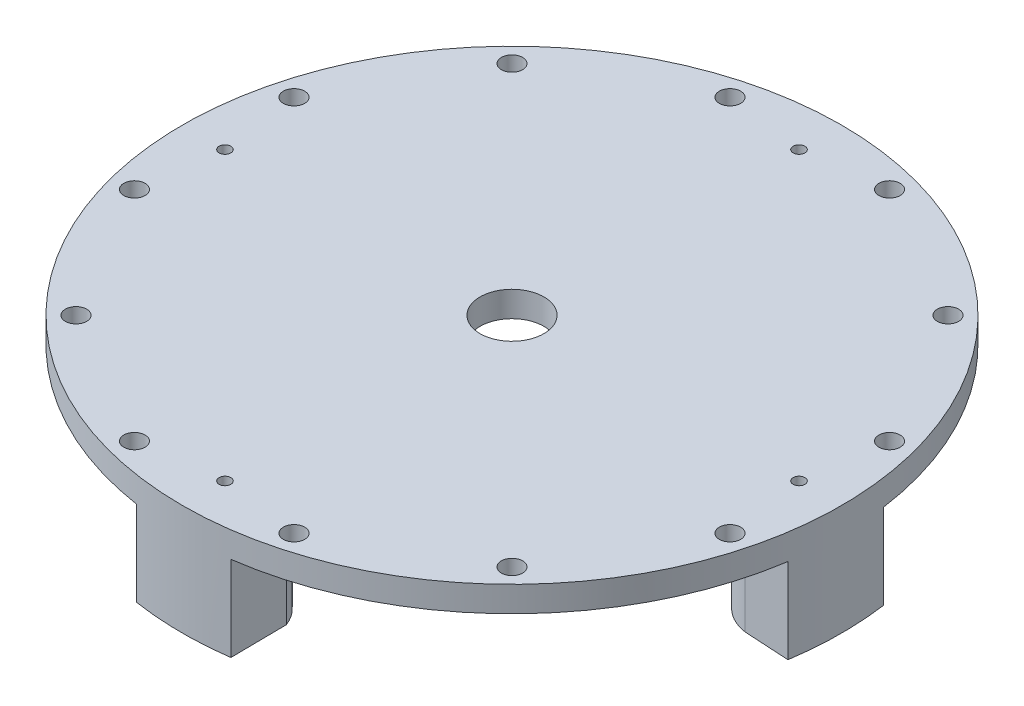
from build123d import *

# Parameters (mm, degrees)
SKETCH1_R           = 98.425
SKETCH1_R_2         = 9.525
BOSS_EXTRUDE1_DEPTH = 7.62
BOSS_EXTRUDE2_DEPTH = 25.4
SKETCH5_R           = 5.2578
CUT_EXTRUDE3_DEPTH  = 19.05
SKETCH6_R           = 3.175
CUT_EXTRUDE4_DEPTH  = 12.7
CIRPATTERN1_COUNT   = 12
CIRPATTERN2_COUNT   = 4
SKETCH8_R           = 1.7526
CUT_EXTRUDE6_DEPTH  = 34.02
CIRPATTERN3_COUNT   = 4


with BuildPart() as part:
    # Sketch1 → Boss-Extrude1 (new body)
    with BuildSketch(Plane(origin=(0, 0, 0), x_dir=(1, 0, 0), z_dir=(0, 1, 0))):
        Circle(SKETCH1_R)
        Circle(SKETCH1_R_2, mode=Mode.SUBTRACT)
    extrude(amount=BOSS_EXTRUDE1_DEPTH)

    # Sketch2 → Boss-Extrude2 (add)
    with BuildSketch(Plane.XZ):
        with BuildLine():
            Line((-14.092921054, 83.751577801), (-14.875155352, 97.29445194))
            ThreePointArc((-14.875155352, 97.29445194), (-0.679076319, 98.422657353), (13.531218764, 97.490444372))
            Line((13.531218764, 97.490444372), (13.333659481, 80.753245397))
            ThreePointArc((13.333659481, 80.753245397), (-1.546485964, 71.578862712), (-14.092921054, 83.751577801))
        make_face()
        with BuildLine():
            Line((83.751577801, 14.092921054), (97.29445194, 14.875155352))
            ThreePointArc((97.29445194, 14.875155352), (98.422657353, 0.679076319), (97.490444372, -13.531218764))
            Line((97.490444372, -13.531218764), (80.753245397, -13.333659481))
            ThreePointArc((80.753245397, -13.333659481), (71.578862712, 1.546485964), (83.751577801, 14.092921054))
        make_face()
        with BuildLine():
            Line((14.092921054, -83.751577801), (14.875155352, -97.29445194))
            ThreePointArc((14.875155352, -97.29445194), (0.679076319, -98.422657353), (-13.531218764, -97.490444372))
            Line((-13.531218764, -97.490444372), (-13.333659481, -80.753245397))
            ThreePointArc((-13.333659481, -80.753245397), (1.546485964, -71.578862712), (14.092921054, -83.751577801))
        make_face()
        with BuildLine():
            Line((-83.751577801, -14.092921054), (-97.29445194, -14.875155352))
            ThreePointArc((-97.29445194, -14.875155352), (-98.422657353, -0.679076319), (-97.490444372, 13.531218764))
            Line((-97.490444372, 13.531218764), (-80.753245397, 13.333659481))
            ThreePointArc((-80.753245397, 13.333659481), (-71.578862712, -1.546485964), (-83.751577801, -14.092921054))
        make_face()
    extrude(amount=BOSS_EXTRUDE2_DEPTH)

    # Sketch5 → Cut-Extrude3 (cut)
    with BuildSketch(Plane.XZ.offset(25.4)):
        with Locations((0, 85.725)):
            Circle(SKETCH5_R)
    cut_extrude3 = extrude(amount=-CUT_EXTRUDE3_DEPTH, mode=Mode.SUBTRACT)

    # Sketch6 → Cut-Extrude4 (cut)
    with BuildSketch(Plane(origin=(0, 7.62, 0), x_dir=(1, 0, 0), z_dir=(0, 1, 0))):
        with Locations((-23.830763578, 88.937620456)):
            Circle(SKETCH6_R)
    cut_extrude4 = extrude(amount=-CUT_EXTRUDE4_DEPTH, mode=Mode.SUBTRACT)

    # CirPattern1: Cut-Extrude4 ×12 about axis
    cirpattern1_axis = Axis((0, 0, 0), (0, 1, 0))
    for i in range(1, CIRPATTERN1_COUNT):
        add(cut_extrude4.rotate(cirpattern1_axis, i * 360 / CIRPATTERN1_COUNT), mode=Mode.SUBTRACT)

    # CirPattern2: Cut-Extrude3 ×4 about axis
    cirpattern2_axis = Axis((0, 0, 0), (0, 1, 0))
    for i in range(1, CIRPATTERN2_COUNT):
        add(cut_extrude3.rotate(cirpattern2_axis, i * 360 / CIRPATTERN2_COUNT), mode=Mode.SUBTRACT)

    # Sketch8 → Cut-Extrude6 (cut, through all)
    with BuildSketch(Plane(origin=(0, 7.62, 0), x_dir=(1, 0, 0), z_dir=(0, 1, 0))):
        with Locations((0, 85.725)):
            Circle(SKETCH8_R)
    cut_extrude6 = extrude(amount=-CUT_EXTRUDE6_DEPTH, mode=Mode.SUBTRACT)

    # CirPattern3: Cut-Extrude6 ×4 about axis
    cirpattern3_axis = Axis((0, 0, 0), (0, 1, 0))
    for i in range(1, CIRPATTERN3_COUNT):
        add(cut_extrude6.rotate(cirpattern3_axis, i * 360 / CIRPATTERN3_COUNT), mode=Mode.SUBTRACT)


solid = part.part
